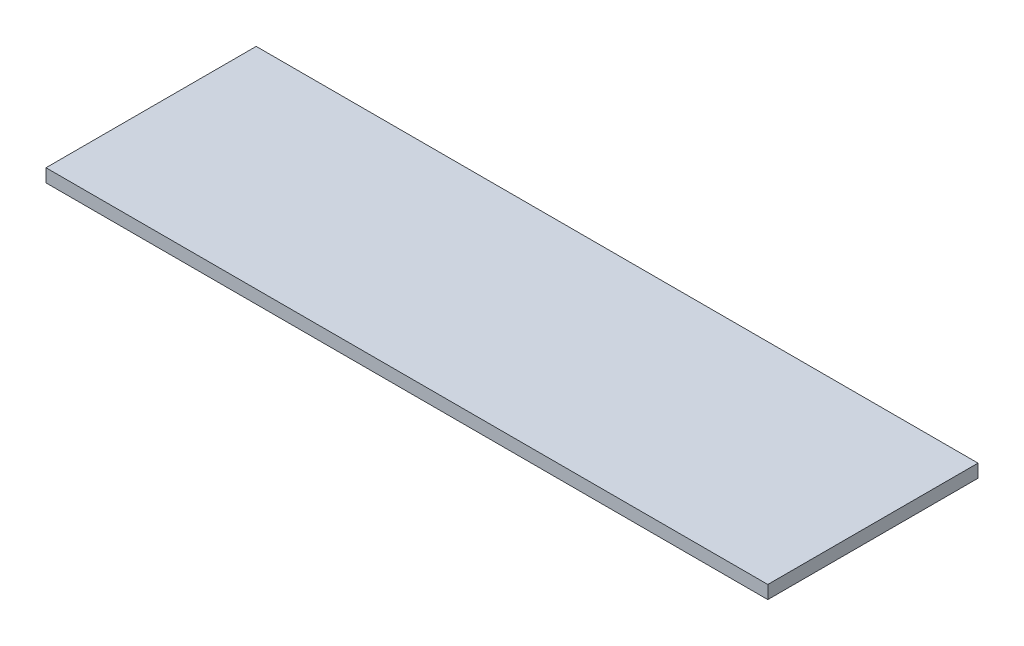
from build123d import *

# Parameters (mm, degrees)
SKETCH1_W           = 989
SKETCH1_H           = 288
BOSS_EXTRUDE1_DEPTH = 18


with BuildPart() as part:
    # Sketch1 → Boss-Extrude1 (new body)
    with BuildSketch(Plane(origin=(0, 0, 0), x_dir=(1, 0, 0), z_dir=(0, 1, 0))):
        Rectangle(SKETCH1_W, SKETCH1_H)
    extrude(amount=BOSS_EXTRUDE1_DEPTH)


solid = part.part
